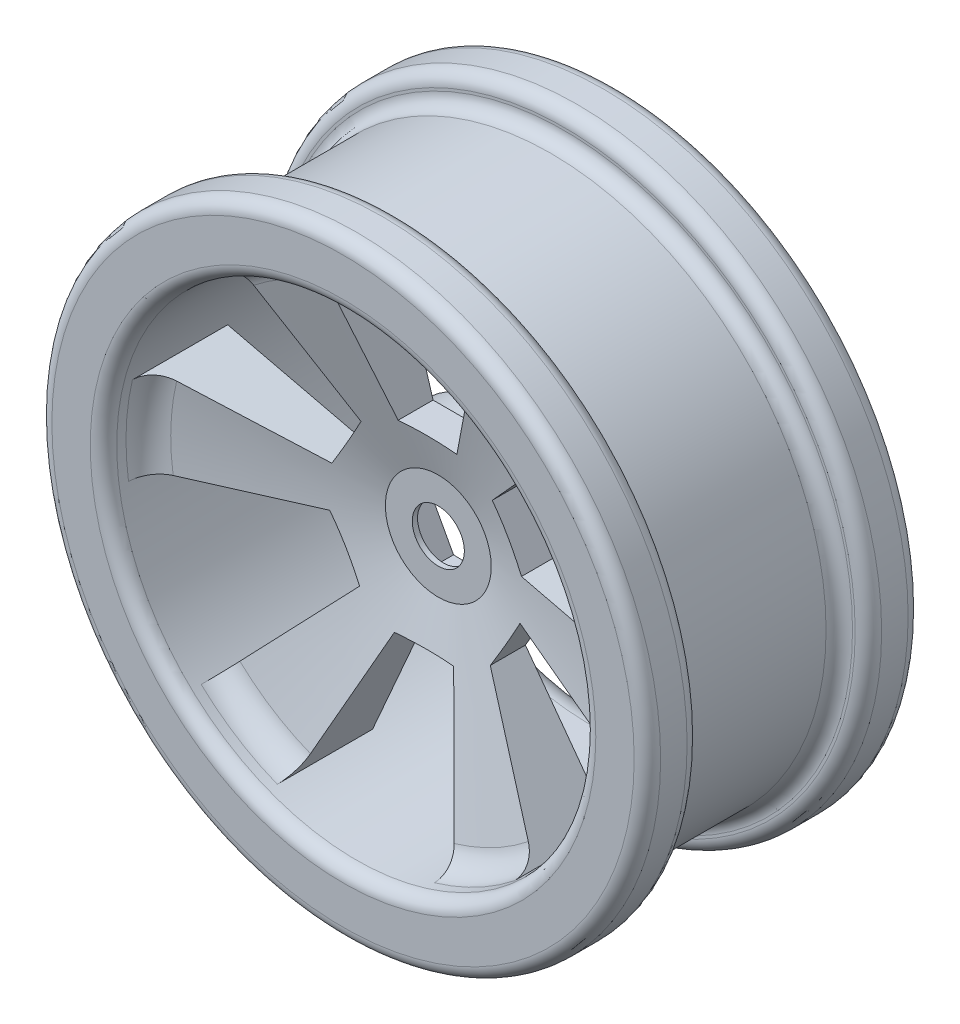
from build123d import *

# Parameters (mm, degrees)
NUT_START         = -5.715
NUT_DEPTH         = 4.572
SPOKES_START      = -18.78
SPOKES_DEPTH      = 28.289
CIRPATTERN1_COUNT = 6
SKETCH2_4_R       = 2.5
AXLE_DEPTH        = 9.509
AXLE_DEPTH_BACK   = 18.78


with BuildPart() as part:
    # Sketch1 → Body (revolve)
    with BuildSketch(Plane(origin=(0, 0, 0), x_dir=(0, 0, -1), z_dir=(1, 0, 0))):
        with BuildLine():
            ThreePointArc((15.24, 22.987), (17.036051, 23.730949), (17.78, 25.527))
            Line((17.78, 25.527), (17.78, 27.94))
            ThreePointArc((17.78, 27.94), (17.408026, 28.838026), (16.51, 29.21))
            Line((16.51, 29.21), (13.97, 29.21))
            ThreePointArc((13.97, 29.21), (13.071974, 28.838026), (12.7, 27.94))
            Line((12.7, 27.94), (12.7, 27.686))
            ThreePointArc((12.7, 27.686), (12.328026, 26.787974), (11.43, 26.416))
            Line((11.43, 26.416), (-2.159, 26.416))
            ThreePointArc((-2.159, 26.416), (-3.057026, 26.787974), (-3.429, 27.686))
            Line((-3.429, 27.686), (-3.429, 27.94))
            ThreePointArc((-3.429, 27.94), (-3.800974, 28.838026), (-4.699, 29.21))
            Line((-4.699, 29.21), (-7.239, 29.21))
            ThreePointArc((-7.239, 29.21), (-8.137026, 28.838026), (-8.509, 27.94))
            Line((-8.509, 27.94), (-8.509, 24.257))
            ThreePointArc((-8.509, 24.257), (-8.137026, 23.358974), (-7.239, 22.987))
            Line((-7.239, 22.987), (-6.35, 22.987))
            ThreePointArc((-6.35, 22.987), (-4.817667, 22.472724), (-3.90584, 21.138147))
            Line((-3.90584, 21.138147), (0.635, 5.08))
            Line((0.635, 5.08), (0.635, 0))
            Line((0.635, 0), (5.715, 0))
            Line((5.715, 0), (5.715, 8.4709))
            Line((5.715, 8.4709), (2.794, 8.4709))
            Line((2.794, 8.4709), (2.794, 22.987))
            Line((2.794, 22.987), (15.24, 22.987))
        make_face()
    revolve(axis=Axis((0, 0, 0), (0, 0, -1)))

    # Sketch2 → Nut (cut)
    with BuildSketch(Plane.XY.offset(NUT_START)):
        Polygon((3.304222, -6.089509), (6.92578, -0.183215), (3.621559, 5.906294), (-3.304222, 6.089509), (-6.92578, 0.183215), (-3.621559, -5.906294), align=None)
    extrude(amount=NUT_DEPTH, mode=Mode.SUBTRACT)

    # Sketch2_3 → Spokes (cut)
    with BuildSketch(Plane.XY.offset(SPOKES_START)):
        with BuildLine():
            Line((-2.663627, 8.89), (2.9969, 8.89))
            Line((2.9969, 8.89), (8.469983, 21.369641))
            ThreePointArc((8.469983, 21.369641), (0.991034, 22.965627), (-6.5976, 22.019851))
            Line((-6.5976, 22.019851), (-2.663627, 8.89))
        make_face()
    spokes = extrude(amount=SPOKES_DEPTH, mode=Mode.SUBTRACT)

    # CirPattern1: Spokes ×6 about axis
    cirpattern1_axis = Axis((0, 0, 0), (0, 0, 1))
    for i in range(1, CIRPATTERN1_COUNT):
        add(spokes.rotate(cirpattern1_axis, i * 360 / CIRPATTERN1_COUNT), mode=Mode.SUBTRACT)

    # Sketch2_4 → Axle (cut, two sides)
    with BuildSketch(Plane.XY) as axle_sk:
        Circle(SKETCH2_4_R)
    extrude(amount=AXLE_DEPTH, mode=Mode.SUBTRACT)
    extrude(axle_sk.sketch, amount=-AXLE_DEPTH_BACK, mode=Mode.SUBTRACT)


solid = part.part
